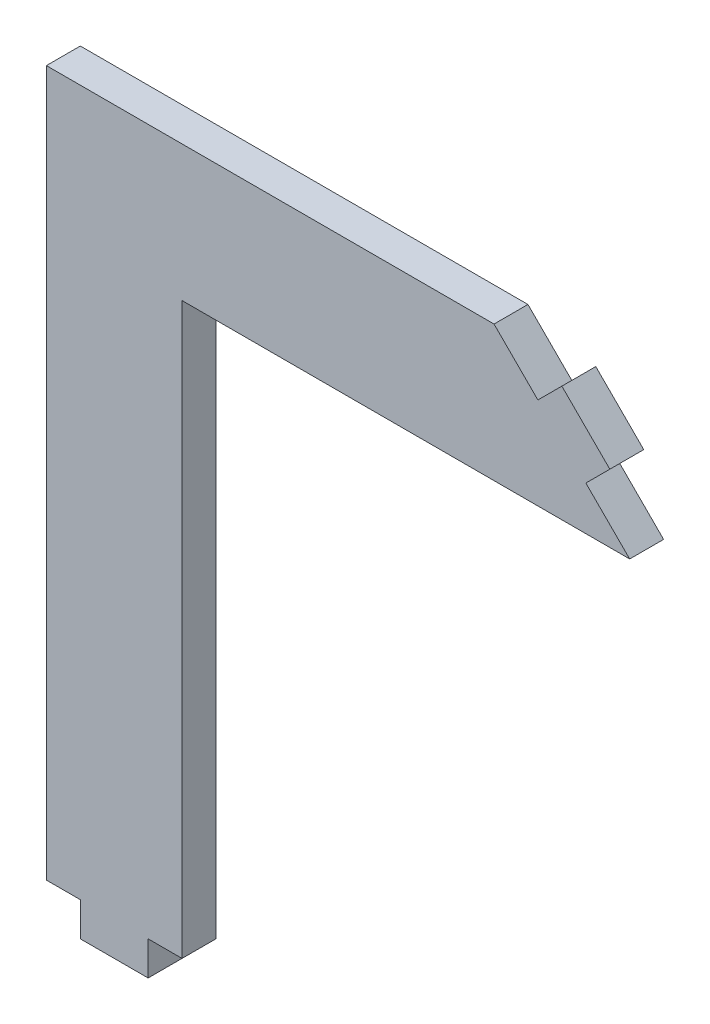
from build123d import *

# Parameters (mm, degrees)
SKETCH1_W           = 12.7
SKETCH1_H           = 12.7
BOSS_EXTRUDE1_DEPTH = 3.175
CUT_EXTRUDE1_DEPTH  = 4.175
SKETCH4_W           = 3.175
SKETCH4_H           = 6.35
BOSS_EXTRUDE3_DEPTH = 3.175
SKETCH5_W           = 3.175
SKETCH5_H           = 12.7
BOSS_EXTRUDE4_DEPTH = 41.91
SKETCH6_W           = 12.7
SKETCH6_H           = 3.175
BOSS_EXTRUDE5_DEPTH = 53.34
SKETCH7_W           = 6.35
SKETCH7_H           = 3.175
BOSS_EXTRUDE6_DEPTH = 3.175


with BuildPart() as part:
    # Sketch1 → Boss-Extrude1 (new body)
    with BuildSketch(Plane.XY):
        with Locations((6.35, -6.35)):
            Rectangle(SKETCH1_W, SKETCH1_H)
    extrude(amount=BOSS_EXTRUDE1_DEPTH)

    # Sketch3 → Cut-Extrude1 (cut, through all)
    with BuildSketch(Plane(origin=(0, 0, 0), x_dir=(-1, 0, 0), z_dir=(0, 0, -1))):
        Polygon((0, 0), (-12.7, -12.7), (-12.7, 0), align=None)
    extrude(amount=-CUT_EXTRUDE1_DEPTH, mode=Mode.SUBTRACT)

    # Sketch4 → Boss-Extrude3 (add)
    with BuildSketch(Plane(origin=(0, 0, 0), x_dir=(0, 0, -1), z_dir=(0.707106781, 0.707106781, 0))):
        with Locations((-1.5875, -8.980256121)):
            Rectangle(SKETCH4_W, SKETCH4_H)
    extrude(amount=BOSS_EXTRUDE3_DEPTH)

    # Sketch5 → Boss-Extrude4 (add)
    with BuildSketch(Plane.ZY):
        with Locations((1.5875, -6.35)):
            Rectangle(SKETCH5_W, SKETCH5_H)
    extrude(amount=BOSS_EXTRUDE4_DEPTH)

    # Sketch6 → Boss-Extrude5 (add)
    with BuildSketch(Plane(origin=(0, -12.7, 0), x_dir=(-1, 0, 0), z_dir=(0, -1, 0))):
        with Locations((35.56, -1.5875)):
            Rectangle(SKETCH6_W, SKETCH6_H)
    extrude(amount=BOSS_EXTRUDE5_DEPTH)

    # Sketch7 → Boss-Extrude6 (add)
    with BuildSketch(Plane.XZ.offset(66.04)):
        with Locations((-35.56, 1.5875)):
            Rectangle(SKETCH7_W, SKETCH7_H)
    extrude(amount=BOSS_EXTRUDE6_DEPTH)


solid = part.part
